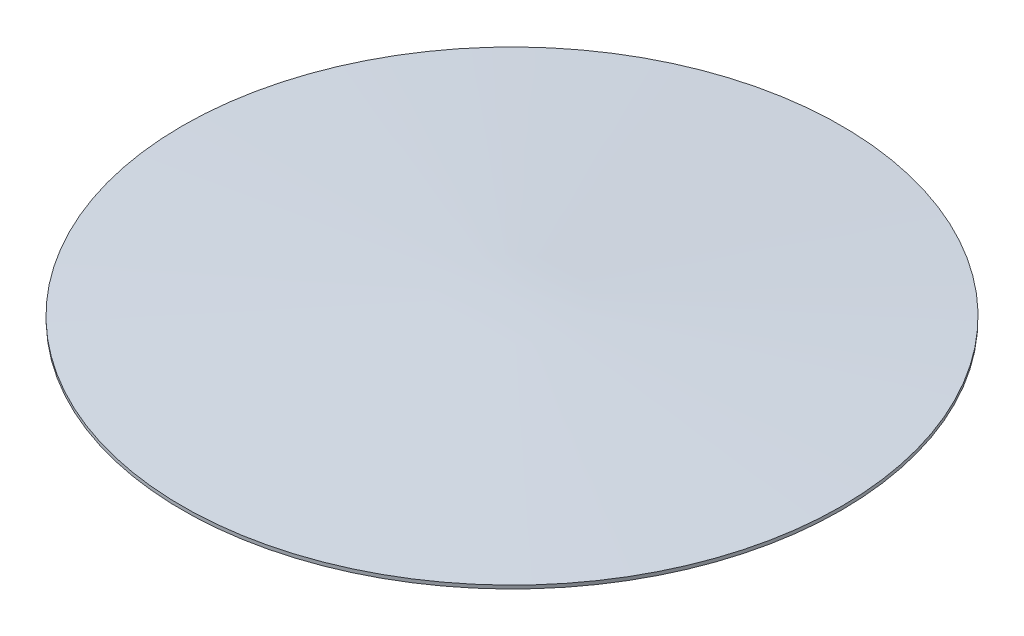
from build123d import *


with BuildPart() as part:
    # Skizze1 → Rotation1 (revolve)
    with BuildSketch(Plane.XY):
        Polygon((0, 0), (0, 2.002872966), (186.60708478, -8.002868845), (186.5, -10), align=None)
    revolve(axis=Axis((0, 0, 0), (0, 1, 0)))


solid = part.part
